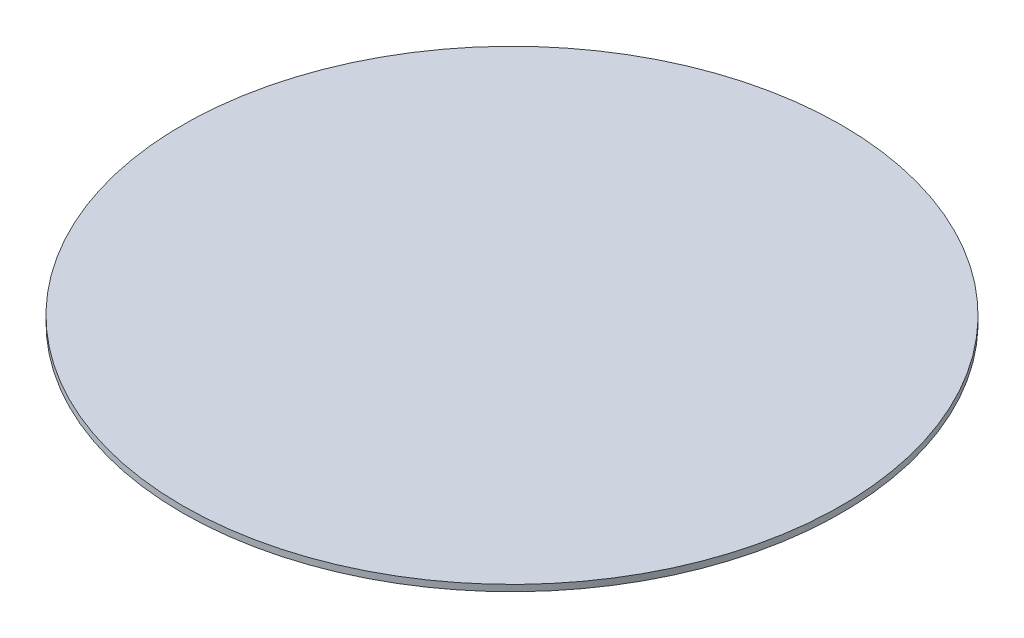
from build123d import *

# Parameters (mm, degrees)
SKETCH1_R           = 165.1
BOSS_EXTRUDE1_DEPTH = 3.175


with BuildPart() as part:
    # Sketch1 → Boss-Extrude1 (new body)
    with BuildSketch(Plane(origin=(0, 0, 0), x_dir=(1, 0, 0), z_dir=(0, 1, 0))):
        Circle(SKETCH1_R)
    extrude(amount=BOSS_EXTRUDE1_DEPTH)


solid = part.part
